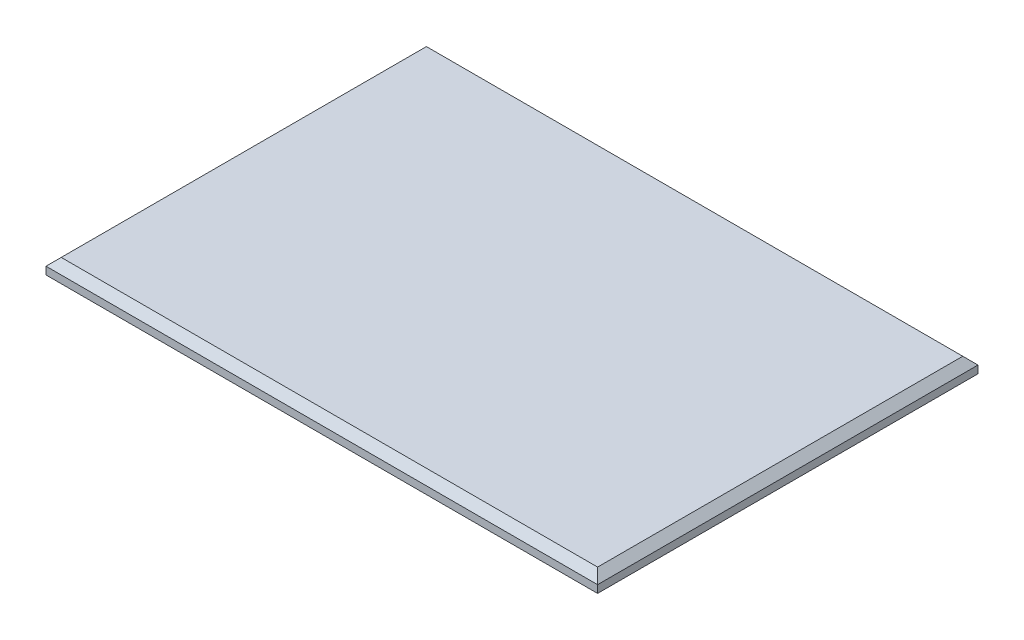
from build123d import *

# Parameters (mm, degrees)
SKETCH1_W           = 145
SKETCH1_H           = 100
BOSS_EXTRUDE1_DEPTH = 4
CHAMFER2_SIZE       = 2


with BuildPart() as part:
    # Sketch1 → Boss-Extrude1 (new body)
    with BuildSketch(Plane(origin=(0, 0, 0), x_dir=(1, 0, 0), z_dir=(0, 1, 0))):
        Rectangle(SKETCH1_W, SKETCH1_H)
    extrude(amount=BOSS_EXTRUDE1_DEPTH)

    # Chamfer2
    chamfer2_edges = [part.edges().sort_by_distance(p)[0] for p in [
        (-72.5, 4, 0),
        (0, 4, 50),
        (72.5, 4, 0),
        (0, 4, -50),
    ]]
    chamfer(chamfer2_edges, length=CHAMFER2_SIZE)


solid = part.part
